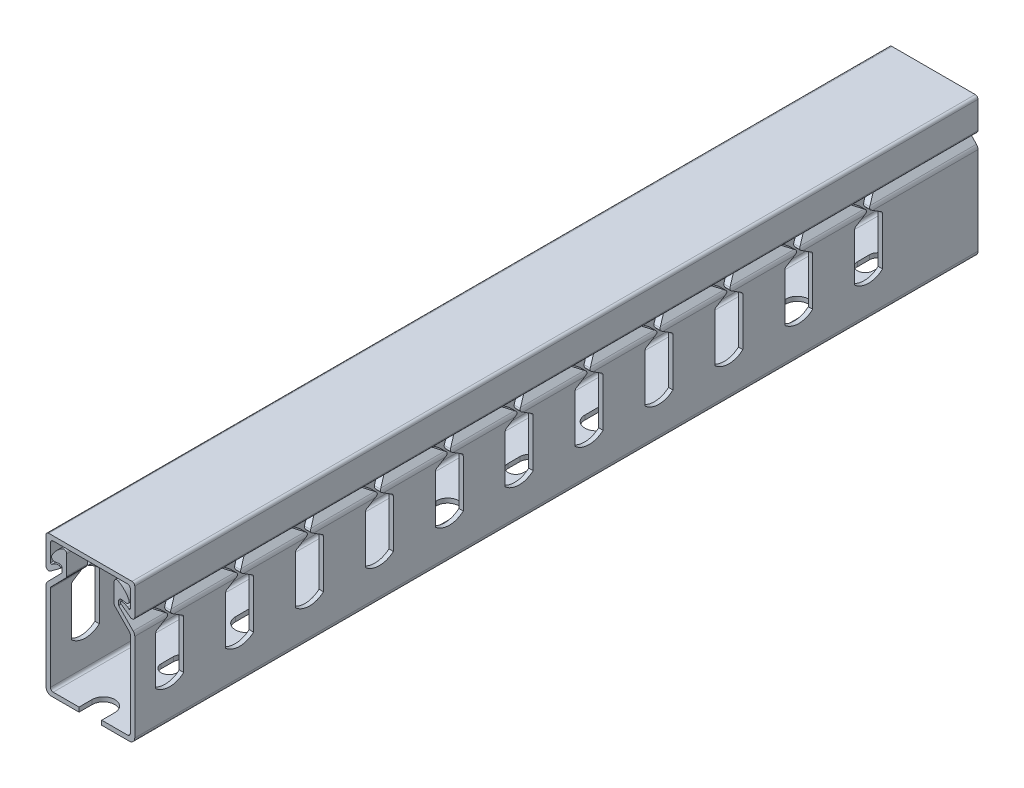
from build123d import *

# Parameters (mm, degrees)
BOSS_EXTRUDE1_DEPTH        = 120.65
BOSS_EXTRUDE1_DEPTH_BACK   = 120.65
BOSS_EXTRUDE1_2_DEPTH      = 120.65
BOSS_EXTRUDE1_2_DEPTH_BACK = 120.65
FILLET1_R                  = 0.254
FILLET2_R                  = 0.79375
FILLET3_R                  = 1.5875
FILLET4_R                  = 0.79375
CUT_EXTRUDE2_DEPTH         = 13.7
LPATTERN2_COUNT            = 11
LPATTERN2_PITCH            = 20
CUT_EXTRUDE3_DEPTH         = 1.27
CUT_EXTRUDE4_DEPTH         = 1.27
LPATTERN3_COUNT            = 6
LPATTERN3_PITCH            = 50


with BuildPart() as part:
    # Sketch5 → Boss-Extrude1 (new body, two sides)
    with BuildSketch(Plane.XY) as boss_extrude1_sk:
        with BuildLine():
            Line((-6.80847, 17.42825), (-6.80847, 11.601073654))
            Line((-6.80847, 11.601073654), (-11.43, 6.8817226))
            Line((-11.43, 6.8817226), (-11.43, -18.73))
            Line((-11.43, -18.73), (11.43, -18.73))
            Line((11.43, -18.73), (11.43, 6.8817226))
            Line((11.43, 6.8817226), (6.80847, 11.601073654))
            Line((6.80847, 11.601073654), (6.80847, 17.42825))
            ThreePointArc((6.80847, 17.42825), (7.19761808, 18.11113824), (7.983490721, 18.124433668))
            ThreePointArc((7.983490721, 18.124433668), (9.75568161, 16.763244384), (11.032082377, 14.929042133))
            ThreePointArc((11.032082377, 14.929042133), (10.954803473, 14.106067876), (10.187743463, 13.798045804))
            Line((10.187743463, 13.798045804), (8.07847, 14.151017128))
            Line((8.07847, 14.151017128), (8.07847, 12.119351053))
            Line((8.07847, 12.119351053), (12.7, 7.4))
            Line((12.7, 7.4), (12.7, -20))
            Line((12.7, -20), (-12.7, -20))
            Line((-12.7, -20), (-12.7, 7.4))
            Line((-12.7, 7.4), (-8.07847, 12.119351053))
            Line((-8.07847, 12.119351053), (-8.07847, 14.151017128))
            Line((-8.07847, 14.151017128), (-10.187743463, 13.798045804))
            ThreePointArc((-10.187743463, 13.798045804), (-10.954803473, 14.106067876), (-11.032082377, 14.929042133))
            ThreePointArc((-11.032082377, 14.929042133), (-9.75568161, 16.763244384), (-7.983490721, 18.124433668))
            ThreePointArc((-7.983490721, 18.124433668), (-7.19761808, 18.11113824), (-6.80847, 17.42825))
        make_face()
    extrude(amount=BOSS_EXTRUDE1_DEPTH)
    extrude(boss_extrude1_sk.sketch, amount=-BOSS_EXTRUDE1_DEPTH_BACK)

    # Fillet3
    fillet3_edges = [part.edges().sort_by_distance(p)[0] for p in [
        (12.7, 7.4, 0),
        (12.7, -20, 0),
        (-12.7, -20, 0),
        (-12.7, 7.4, 0),
    ]]
    fillet(fillet3_edges, radius=FILLET3_R)

    # Fillet4
    fillet4_edges = [part.edges().sort_by_distance(p)[0] for p in [
        (-6.80847, 11.601073654, 0),
        (-11.43, 6.8817226, 0),
        (-11.43, -18.73, 0),
        (11.43, -18.73, 0),
        (11.43, 6.8817226, 0),
        (6.80847, 11.601073654, 0),
        (8.07847, 14.151017128, 0),
        (-8.07847, 14.151017128, 0),
    ]]
    fillet(fillet4_edges, radius=FILLET4_R)

    # Sketch6 → Cut-Extrude2 (cut, symmetric)
    with BuildSketch(Plane(origin=(0, 0, 0), x_dir=(0, 0, -1), z_dir=(1, 0, 0))):
        with BuildLine():
            Line((-114.65, 20), (-114.65, 10.281402782))
            ThreePointArc((-114.65, 10.281402782), (-114.551317282, 9.898100634), (-114.279806522, 9.610106323))
            Line((-114.279806522, 9.610106323), (-111.308970247, 7.735648229))
            ThreePointArc((-111.308970247, 7.735648229), (-111.123873508, 7.4), (-111.308970247, 7.064351771))
            Line((-111.308970247, 7.064351771), (-114.279806522, 5.189893677))
            ThreePointArc((-114.279806522, 5.189893677), (-114.551317282, 4.901899366), (-114.65, 4.518597218))
            Line((-114.65, 4.518597218), (-114.65, -9.1796))
            ThreePointArc((-114.65, -9.1796), (-110.65, -10.707464045), (-106.65, -9.1796))
            Line((-106.65, -9.1796), (-106.65, 4.518597218))
            ThreePointArc((-106.65, 4.518597218), (-106.748682718, 4.901899366), (-107.020193478, 5.189893677))
            Line((-107.020193478, 5.189893677), (-109.991029753, 7.064351771))
            ThreePointArc((-109.991029753, 7.064351771), (-110.176126492, 7.4), (-109.991029753, 7.735648229))
            Line((-109.991029753, 7.735648229), (-107.020193478, 9.610106323))
            ThreePointArc((-107.020193478, 9.610106323), (-106.748682718, 9.898100634), (-106.65, 10.281402782))
            Line((-106.65, 10.281402782), (-106.65, 20))
            Line((-106.65, 20), (-114.65, 20))
        make_face()
    cut_extrude2 = extrude(amount=CUT_EXTRUDE2_DEPTH, both=True, mode=Mode.SUBTRACT)

    # LPattern2: Cut-Extrude2 ×11
    with Locations(*[(0, 0, -i * LPATTERN2_PITCH) for i in range(1, LPATTERN2_COUNT)]):
        add(cut_extrude2, mode=Mode.SUBTRACT)

    # Sketch7 → Cut-Extrude3 (cut)
    with BuildSketch(Plane.XZ.offset(20)):
        with BuildLine():
            Line((-3.25, 124.4), (-3.25, 116.9))
            ThreePointArc((-3.25, 116.9), (0, 113.65), (3.25, 116.9))
            Line((3.25, 116.9), (3.25, 124.4))
            ThreePointArc((3.25, 124.4), (0, 127.65), (-3.25, 124.4))
        make_face()
        with BuildLine():
            Line((-2.25, 98.15), (-2.25, 94.65))
            ThreePointArc((-2.25, 94.65), (0, 92.4), (2.25, 94.65))
            Line((2.25, 94.65), (2.25, 98.15))
            ThreePointArc((2.25, 98.15), (0, 100.4), (-2.25, 98.15))
        make_face()
    extrude(amount=-CUT_EXTRUDE3_DEPTH, mode=Mode.SUBTRACT)

    # Sketch8 → Cut-Extrude4 (cut)
    with BuildSketch(Plane.XZ.offset(20)):
        with BuildLine():
            Line((-2.25, 45.4), (-2.25, 48.9))
            ThreePointArc((-2.25, 48.9), (0, 51.15), (2.25, 48.9))
            Line((2.25, 48.9), (2.25, 45.4))
            ThreePointArc((2.25, 45.4), (0, 43.15), (-2.25, 45.4))
        make_face()
        with BuildLine():
            Line((3.25, 75.9), (3.25, 68.4))
            ThreePointArc((3.25, 68.4), (0, 65.15), (-3.25, 68.4))
            Line((-3.25, 68.4), (-3.25, 75.9))
            ThreePointArc((-3.25, 75.9), (0, 79.15), (3.25, 75.9))
        make_face()
    cut_extrude4 = extrude(amount=-CUT_EXTRUDE4_DEPTH, mode=Mode.SUBTRACT)

    # LPattern3: Cut-Extrude4 ×6
    with Locations(*[(0, 0, -i * LPATTERN3_PITCH) for i in range(1, LPATTERN3_COUNT)]):
        add(cut_extrude4, mode=Mode.SUBTRACT)


with BuildPart() as body_2:
    # Sketch5 → Boss-Extrude1 2 (new body, two sides)
    with BuildSketch(Plane.XY) as boss_extrude1_2_sk:
        with BuildLine():
            Line((-12.7, 20), (-12.7, 11.49227))
            ThreePointArc((-12.7, 11.49227), (-12.263515638, 10.783467964), (-11.434109413, 10.854208617))
            Line((-11.434109413, 10.854208617), (-8.751188909, 12.839465357))
            ThreePointArc((-8.751188909, 12.839465357), (-8.610572709, 13.282073626), (-8.98688149, 13.554225599))
            ThreePointArc((-8.98688149, 13.554225599), (-9.873382015, 13.411834461), (-10.670699038, 12.998985842))
            Line((-10.670699038, 12.998985842), (-11.43, 12.437132686))
            Line((-11.43, 12.437132686), (-11.43, 18.73))
            Line((-11.43, 18.73), (11.43, 18.73))
            Line((11.43, 18.73), (11.43, 12.437132686))
            Line((11.43, 12.437132686), (10.670699038, 12.998985842))
            ThreePointArc((10.670699038, 12.998985842), (9.873382015, 13.411834461), (8.98688149, 13.554225599))
            ThreePointArc((8.98688149, 13.554225599), (8.610572709, 13.282073626), (8.751188909, 12.839465357))
            Line((8.751188909, 12.839465357), (11.434109413, 10.854208617))
            ThreePointArc((11.434109413, 10.854208617), (12.263515638, 10.783467964), (12.7, 11.49227))
            Line((12.7, 11.49227), (12.7, 20))
            Line((12.7, 20), (-12.7, 20))
        make_face()
    extrude(amount=BOSS_EXTRUDE1_2_DEPTH)
    extrude(boss_extrude1_2_sk.sketch, amount=-BOSS_EXTRUDE1_2_DEPTH_BACK)

    # Fillet1
    fillet1_edges = [body_2.edges().sort_by_distance(p)[0] for p in [
        (11.43, 12.437132686, 0),
        (-11.43, 12.437132686, 0),
    ]]
    fillet(fillet1_edges, radius=FILLET1_R)

    # Fillet2
    fillet2_edges = [body_2.edges().sort_by_distance(p)[0] for p in [
        (12.7, 20, 0),
        (11.43, 18.73, 0),
        (-11.43, 18.73, 0),
        (-12.7, 20, 0),
    ]]
    fillet(fillet2_edges, radius=FILLET2_R)


solid = Compound([part.part, body_2.part])
